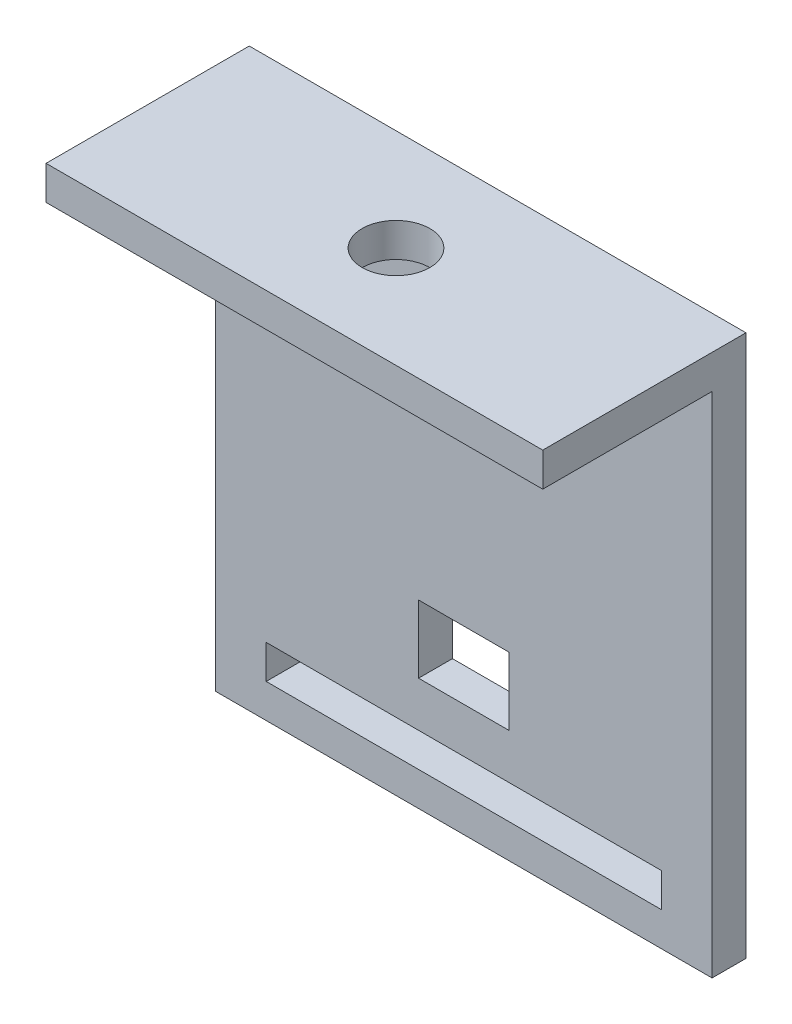
from build123d import *

# Parameters (mm, degrees)
ESTRUSIONE_ESTRUSIONE6_DEPTH = 44
SCHIZZO9_W                   = 35
SCHIZZO9_H                   = 3
TAGLIO_ESTRUSIONE2_DEPTH     = 44
SCHIZZO10_R                  = 3
TAGLIO_ESTRUSIONE3_DEPTH     = 10
SCHIZZO11_W                  = 8
SCHIZZO11_H                  = 6
TAGLIO_ESTRUSIONE4_DEPTH     = 10


with BuildPart() as part:
    # Schizzo8 → Estrusione-Estrusione6 (new body)
    with BuildSketch(Plane(origin=(0, 0, 0), x_dir=(0, 0, -1), z_dir=(1, 0, 0))):
        Polygon((0, 0), (0, 3), (18, 3), (18, -45), (15, -45), (15, 0), align=None)
    extrude(amount=ESTRUSIONE_ESTRUSIONE6_DEPTH)

    # Schizzo9 → Taglio-Estrusione2 (cut)
    with BuildSketch(Plane.XY.offset(-15)):
        with Locations((22, -40.5)):
            Rectangle(SCHIZZO9_W, SCHIZZO9_H)
    extrude(amount=-TAGLIO_ESTRUSIONE2_DEPTH, mode=Mode.SUBTRACT)

    # Schizzo10 → Taglio-Estrusione3 (cut)
    with BuildSketch(Plane(origin=(0, 3, 0), x_dir=(1, 0, 0), z_dir=(0, 1, 0))):
        with Locations((22, 9)):
            Circle(SCHIZZO10_R)
    extrude(amount=-TAGLIO_ESTRUSIONE3_DEPTH, mode=Mode.SUBTRACT)

    # Schizzo11 → Taglio-Estrusione4 (cut)
    with BuildSketch(Plane(origin=(0, 0, -18), x_dir=(-1, 0, 0), z_dir=(0, 0, -1))):
        with Locations((-22, -32)):
            Rectangle(SCHIZZO11_W, SCHIZZO11_H)
    extrude(amount=-TAGLIO_ESTRUSIONE4_DEPTH, mode=Mode.SUBTRACT)


solid = part.part
